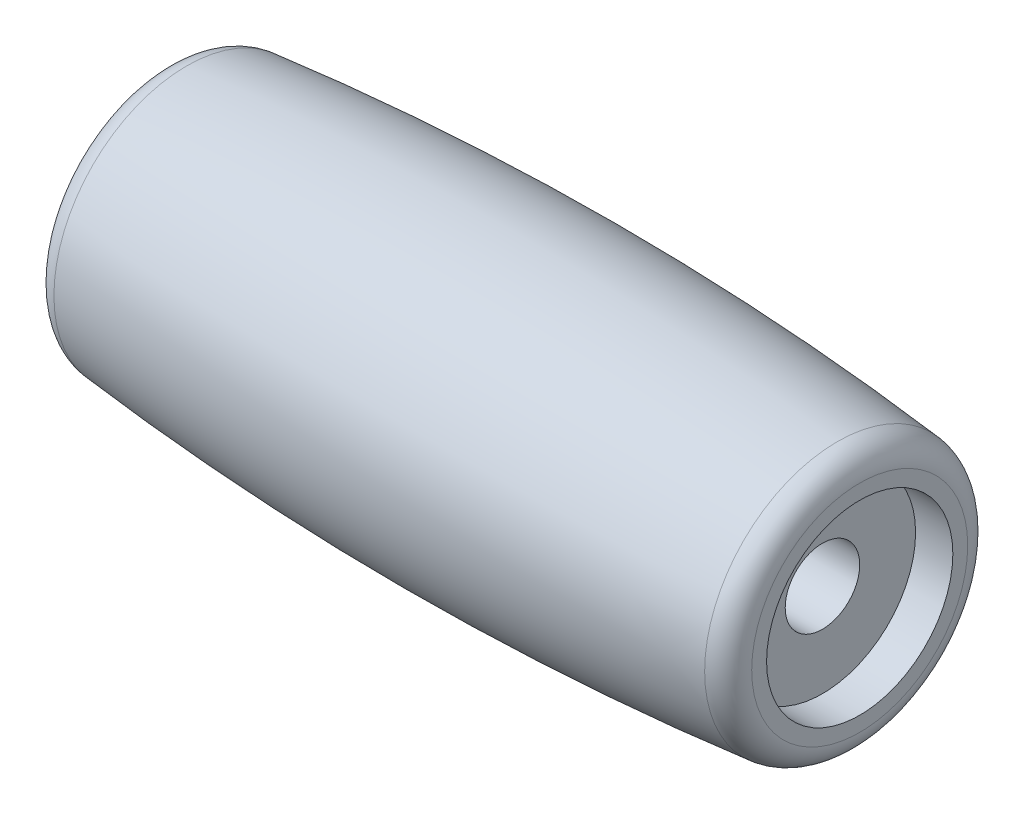
from build123d import *


with BuildPart() as part:
    # Sketch1 → Revolve1 (revolve)
    with BuildSketch(Plane.XY):
        with BuildLine():
            Line((-25, 3), (25, 3))
            Line((25, 3), (25, 7.5))
            Line((25, 7.5), (28, 7.5))
            Line((28, 7.5), (28, 8.69715333))
            ThreePointArc((28, 8.69715333), (27.483218095, 10.038817998), (26.199935918, 10.687134644))
            ThreePointArc((26.199935918, 10.687134644), (0, 12), (-26.199935918, 10.687134644))
            ThreePointArc((-26.199935918, 10.687134644), (-27.483218095, 10.038817998), (-28, 8.69715333))
            Line((-28, 8.69715333), (-28, 7.5))
            Line((-28, 7.5), (-25, 7.5))
            Line((-25, 7.5), (-25, 3))
        make_face()
    revolve(axis=Axis((0, 0, 0), (1, 0, 0)))


solid = part.part
